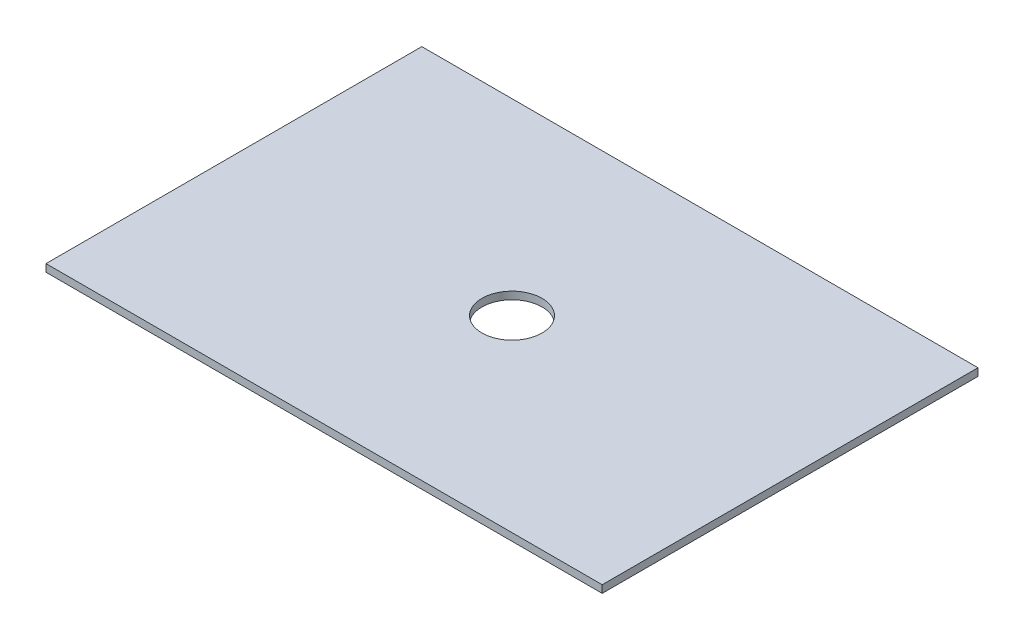
from build123d import *

# Parameters (mm, degrees)
SKETCH1_W           = 469.9
SKETCH1_H           = 317.5
SKETCH1_R           = 25.4
BOSS_EXTRUDE1_DEPTH = 6.35


with BuildPart() as part:
    # Sketch1 → Boss-Extrude1 (new body)
    with BuildSketch(Plane(origin=(0, 0, 0), x_dir=(1, 0, 0), z_dir=(0, 1, 0))):
        with Locations((234.95, 158.75)):
            Rectangle(SKETCH1_W, SKETCH1_H)
        with Locations((234.95, 158.75)):
            Circle(SKETCH1_R, mode=Mode.SUBTRACT)
    extrude(amount=BOSS_EXTRUDE1_DEPTH)


solid = part.part
